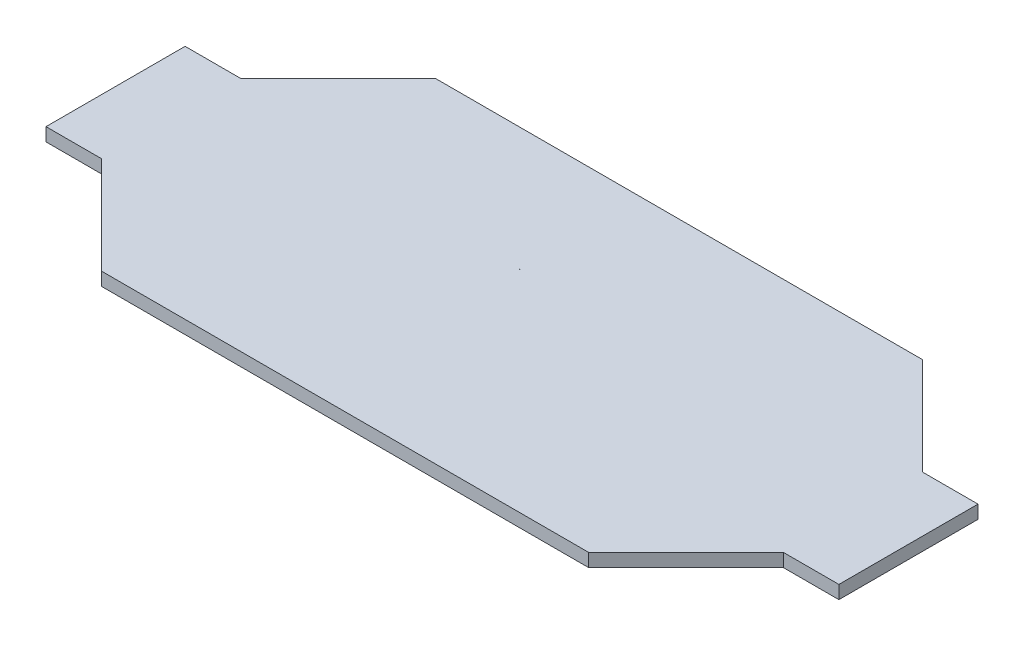
from build123d import *

# Parameters (mm, degrees)
BOSS_EXTRUDE2_DEPTH = 4.75


with BuildPart() as part:
    # Sketch1 → Boss-Extrude2 (new body)
    with BuildSketch(Plane(origin=(0, 0, 0), x_dir=(1, 0, 0), z_dir=(0, 1, 0))):
        Polygon((100, 60), (-75, 60), (-110, 25), (-130, 25), (-130, -25), (-110, -25), (-75, -60), (100, -60), (135, -25), (155, -25), (155, 25), (135, 25), align=None)
        with BuildLine():
            ThreePointArc((-0.096105451, 15.808688779), (-0.437294407, 15.700808335), (-0.778483364, 15.808688779))
            Line((-0.778483364, 15.808688779), (-0.096105451, 15.808688779))
        make_face(mode=Mode.SUBTRACT)
    extrude(amount=BOSS_EXTRUDE2_DEPTH)


solid = part.part
